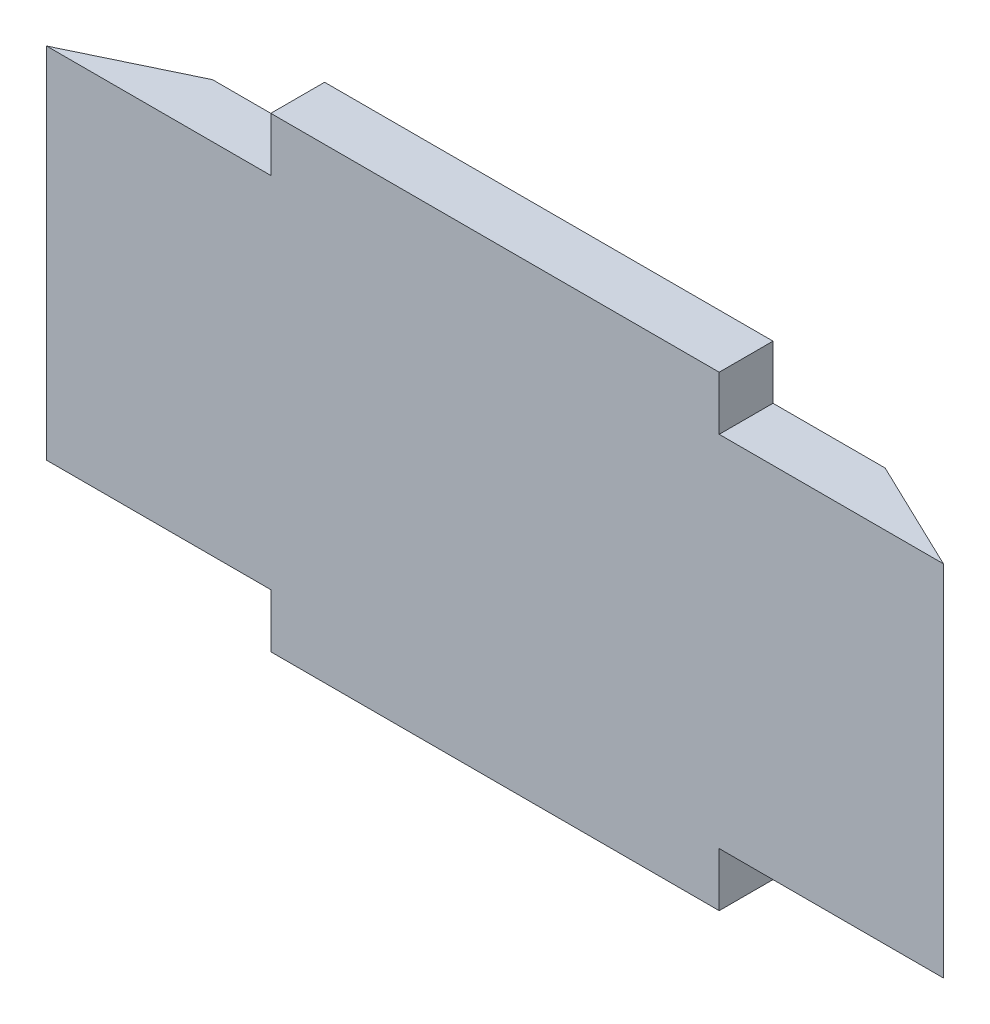
from build123d import *

# Parameters (mm, degrees)
ESQUISSE1_W             = 100
ESQUISSE1_H             = 40
BOSS_EXTRU_1_DEPTH      = 6
ESQUISSE2_W             = 50
ESQUISSE2_H             = 6
BOSS_EXTRU_2_DEPTH      = 6
ENL_V_MAT_EXTRU_1_DEPTH = 47


with BuildPart() as part:
    # Esquisse1 → Boss.-Extru.1 (new body)
    with BuildSketch(Plane.XY):
        Rectangle(ESQUISSE1_W, ESQUISSE1_H)
    extrude(amount=BOSS_EXTRU_1_DEPTH)

    # Esquisse2 → Boss.-Extru.2 (add)
    with BuildSketch(Plane.XY.offset(6)):
        with Locations((0, 23)):
            Rectangle(ESQUISSE2_W, ESQUISSE2_H)
        with Locations((0, -23)):
            Rectangle(ESQUISSE2_W, ESQUISSE2_H)
    extrude(amount=-BOSS_EXTRU_2_DEPTH)

    # Esquisse3 → Enlèv. mat.-Extru.1 (cut, through all)
    with BuildSketch(Plane(origin=(0, 20, 0), x_dir=(1, 0, 0), z_dir=(0, 1, 0))):
        Polygon((-50, -6), (-37.5, 0), (-50, 0), align=None)
        Polygon((50, -6), (37.5, 0), (50, 0), align=None)
    extrude(amount=-ENL_V_MAT_EXTRU_1_DEPTH, mode=Mode.SUBTRACT)


solid = part.part
